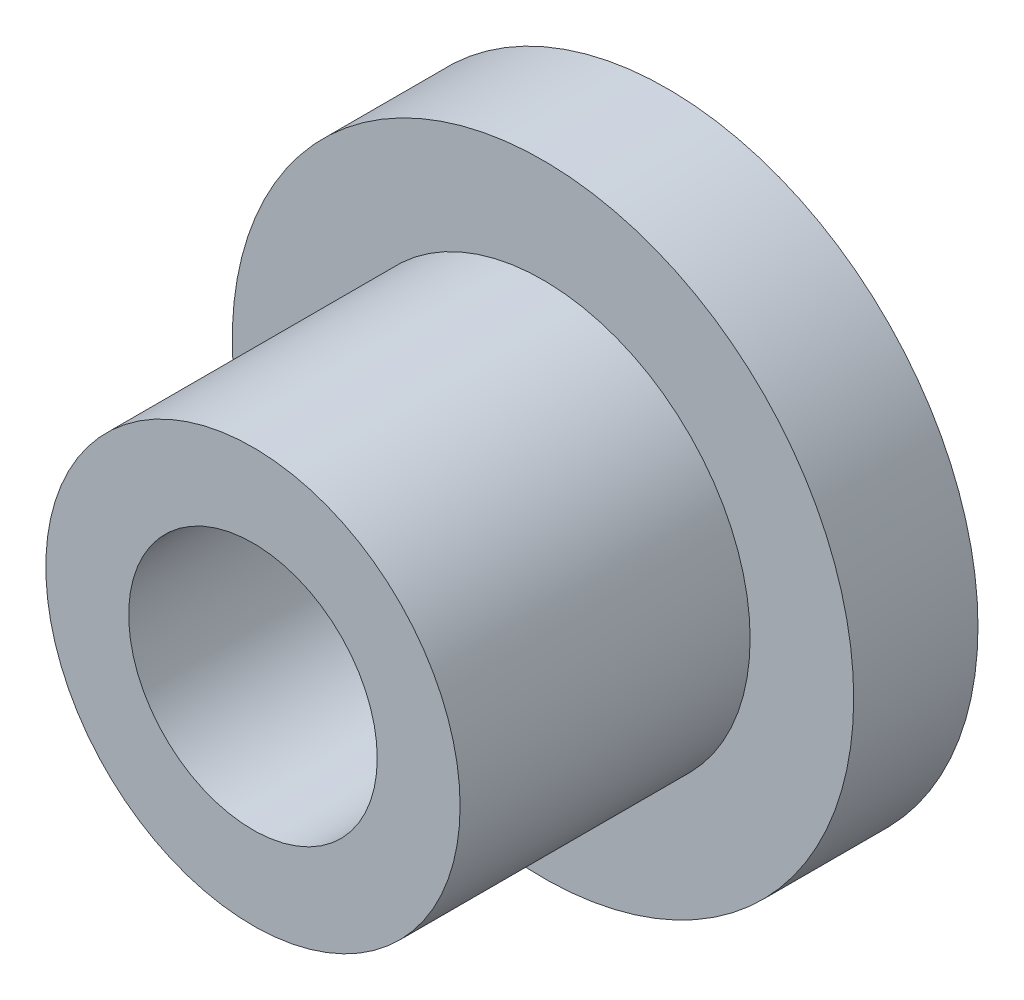
from build123d import *

# Parameters (mm, degrees)
IZIM1_R                     = 15
Y_KSEKLIK_EKSTR_ZYON1_DEPTH = 6
IZIM2_R                     = 10
Y_KSEKLIK_EKSTR_ZYON2_DEPTH = 14
IZIM3_R                     = 6
KES_EKSTR_ZYON1_DEPTH       = 21


with BuildPart() as part:
    # Çizim1 → Yükseklik-Ekstrüzyon1 (new body)
    with BuildSketch(Plane.XY):
        Circle(IZIM1_R)
    extrude(amount=Y_KSEKLIK_EKSTR_ZYON1_DEPTH)

    # Çizim2 → Yükseklik-Ekstrüzyon2 (add)
    with BuildSketch(Plane.XY.offset(6)):
        Circle(IZIM2_R)
    extrude(amount=Y_KSEKLIK_EKSTR_ZYON2_DEPTH)

    # Çizim3 → Kes-Ekstrüzyon1 (cut, through all)
    with BuildSketch(Plane.XY.offset(20)):
        Circle(IZIM3_R)
    extrude(amount=-KES_EKSTR_ZYON1_DEPTH, mode=Mode.SUBTRACT)


solid = part.part
